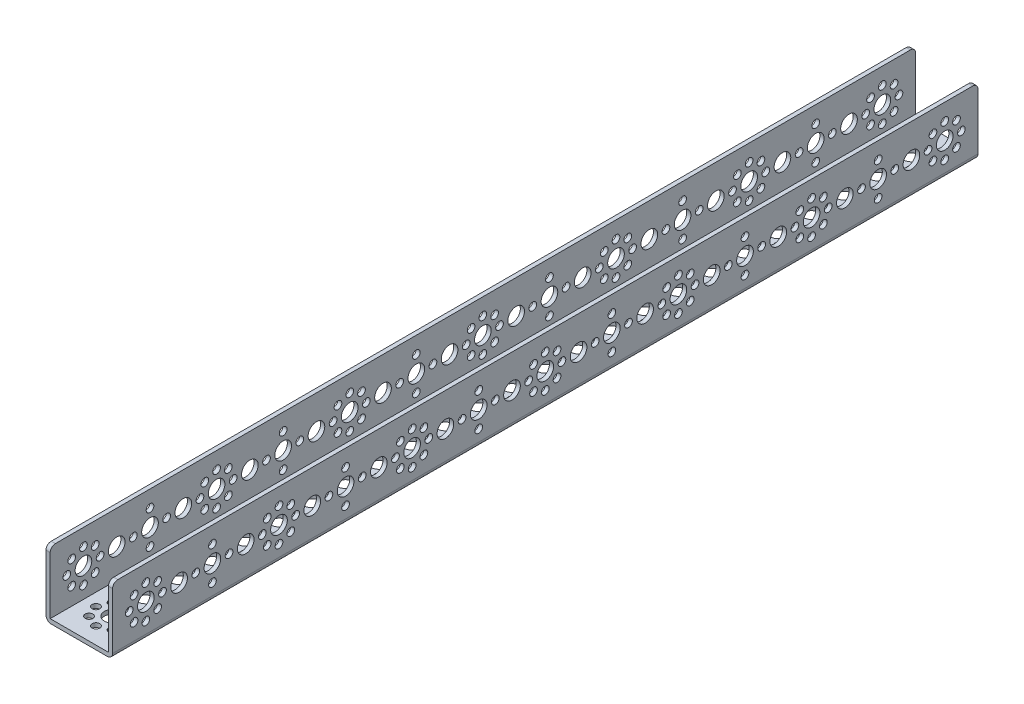
from build123d import *

# Parameters (mm, degrees)
SKETCH1_W                      = 32
SKETCH1_H                      = 416
BOSS_EXTRUDE1_DEPTH            = 32
SKETCH2_W                      = 28
SKETCH2_H                      = 30
CUT_EXTRUDE1_DEPTH             = 417
F_8_0_8_DIAMETER_HOLE1_D       = 8
F_8_0_8_DIAMETER_HOLE1_DEPTH   = 2
F_8_0_8_DIAMETER_HOLE2_D       = 8
F_8_0_8_DIAMETER_HOLE2_DEPTH   = 2
F_3_7_3_7_DIAMETER_HOLE1_D     = 3.7
F_3_7_3_7_DIAMETER_HOLE1_DEPTH = 2
F_3_7_3_7_DIAMETER_HOLE2_D     = 3.7
F_3_7_3_7_DIAMETER_HOLE2_DEPTH = 32
F_8_0_8_DIAMETER_HOLE3_D       = 8
F_8_0_8_DIAMETER_HOLE3_DEPTH   = 32
F_8_0_8_DIAMETER_HOLE4_D       = 8
F_8_0_8_DIAMETER_HOLE4_DEPTH   = 32
F_3_7_3_7_DIAMETER_HOLE3_D     = 3.7
F_3_7_3_7_DIAMETER_HOLE3_DEPTH = 32
FILLET1_R                      = 2.5


with BuildPart() as part:
    # Sketch1 → Boss-Extrude1 (new body)
    with BuildSketch(Plane(origin=(-16, 0, 0), x_dir=(0, -1, 0), z_dir=(-1, 0, 0))):
        with Locations((-16, -192)):
            Rectangle(SKETCH1_W, SKETCH1_H)
    extrude(amount=-BOSS_EXTRUDE1_DEPTH)

    # Sketch2 → Cut-Extrude1 (cut, through all)
    with BuildSketch(Plane.XY.offset(16)):
        with Locations((0, 17)):
            Rectangle(SKETCH2_W, SKETCH2_H)
    extrude(amount=-CUT_EXTRUDE1_DEPTH, mode=Mode.SUBTRACT)

    # Ø8.0 (8) Diameter Hole1
    with Locations(Plane.ZY.offset(-14)):
        with Locations((-32, 16)):
            Hole(F_8_0_8_DIAMETER_HOLE1_D / 2, depth=F_8_0_8_DIAMETER_HOLE1_DEPTH)

    # Ø8.0 (8) Diameter Hole2
    with Locations(Plane(origin=(16, 0, 0), x_dir=(0, 0, -1), z_dir=(1, 0, 0))):
        with Locations((64, 16), (128, 16), (192, 16), (256, 16), (320, 16), (384, 16), (96, 16), (160, 16), (224, 16), (288, 16), (352, 16), (16, 16), (48, 16), (80, 16), (112, 16), (144, 16), (176, 16), (208, 16), (240, 16), (0, 16), (272, 16), (304, 16), (336, 16), (368, 16)):
            Hole(F_8_0_8_DIAMETER_HOLE2_D / 2, depth=F_8_0_8_DIAMETER_HOLE2_DEPTH)

    # Ø3.7 (3.7) Diameter Hole1
    with Locations(Plane(origin=(16, 0, 0), x_dir=(0, 0, -1), z_dir=(1, 0, 0))):
        with Locations((0, 24), (0, 8), (8, 16), (-8, 16), (5.656854249, 21.656854249), (-5.656854249, 21.656854249), (-5.656854249, 10.343145751), (5.656854249, 10.343145751), (64, 24), (64, 8), (72, 16), (56, 16), (69.656854249, 21.656854249), (58.343145751, 21.656854249), (58.343145751, 10.343145751), (69.656854249, 10.343145751), (128, 24), (128, 8), (136, 16), (120, 16), (133.656854249, 21.656854249), (122.34314575, 21.656854249), (122.34314575, 10.343145751), (133.656854249, 10.343145751), (192, 24), (192, 8), (200, 16), (184, 16), (197.656854249, 21.656854249), (186.343145751, 21.656854249), (186.343145751, 10.343145751), (197.656854249, 10.343145751), (256, 24), (256, 8), (264, 16), (248, 16), (261.656854249, 21.656854249), (250.343145751, 21.656854249), (250.343145751, 10.343145751), (261.656854249, 10.343145751), (320, 24), (320, 8), (328, 16), (312, 16), (325.656854249, 21.656854249), (314.343145751, 21.656854249), (314.343145751, 10.343145751), (325.656854249, 10.343145751), (384, 24), (384, 8), (392, 16), (376, 16), (389.656854249, 21.656854249), (378.343145751, 21.656854249), (378.343145751, 10.343145751), (389.656854249, 10.343145751), (32, 24), (40, 16), (32, 8), (24, 16), (96, 24), (104, 16), (96, 8), (88, 16), (160, 24), (168, 16), (160, 8), (152, 16), (224, 24), (232, 16), (224, 8), (216, 16), (288, 24), (296, 16), (288, 8), (280, 16), (352, 24), (360, 16), (352, 8), (344, 16)):
            Hole(F_3_7_3_7_DIAMETER_HOLE1_D / 2, depth=F_3_7_3_7_DIAMETER_HOLE1_DEPTH)

    # Ø3.7 (3.7) Diameter Hole2
    with Locations(Plane(origin=(0, 0, 0), x_dir=(-1, 0, 0), z_dir=(0, -1, 0))):
        with Locations((8, 0), (5.656854249, 5.656854249), (0, 8), (-5.656854249, 5.656854249), (-8, 0), (-5.656854249, -5.656854249), (0, -8), (5.656854249, -5.656854249), (8, 64), (5.656854249, 69.656854249), (0, 72), (-5.656854249, 69.656854249), (-8, 64), (-5.656854249, 58.343145751), (0, 56), (5.656854249, 58.343145751), (8, 128), (5.656854249, 133.656854249), (0, 136), (-5.656854249, 133.656854249), (-8, 128), (-5.656854249, 122.34314575), (0, 120), (5.656854249, 122.34314575), (8, 192), (5.656854249, 197.656854249), (0, 200), (-5.656854249, 197.656854249), (-8, 192), (-5.656854249, 186.343145751), (0, 184), (5.656854249, 186.343145751), (8, 256), (5.656854249, 261.656854249), (0, 264), (-5.656854249, 261.656854249), (-8, 256), (-5.656854249, 250.343145751), (0, 248), (5.656854249, 250.343145751), (8, 320), (5.656854249, 325.656854249), (0, 328), (-5.656854249, 325.656854249), (-8, 320), (-5.656854249, 314.343145751), (0, 312), (5.656854249, 314.343145751), (8, 384), (5.656854249, 389.656854249), (0, 392), (-5.656854249, 389.656854249), (-8, 384), (-5.656854249, 378.343145751), (0, 376), (5.656854249, 378.343145751), (8, 32), (0, 40), (-8, 32), (0, 24), (8, 96), (0, 104), (-8, 96), (0, 88), (8, 160), (0, 168), (-8, 160), (0, 152), (8, 224), (0, 232), (-8, 224), (0, 216), (8, 288), (0, 296), (-8, 288), (0, 280), (8, 352), (0, 360), (-8, 352), (0, 344)):
            Hole(F_3_7_3_7_DIAMETER_HOLE2_D / 2, depth=F_3_7_3_7_DIAMETER_HOLE2_DEPTH)

    # Ø8.0 (8) Diameter Hole3
    with Locations(Plane(origin=(0, 0, 0), x_dir=(-1, 0, 0), z_dir=(0, -1, 0))):
        with Locations((0, 0), (0, 64), (0, 128), (0, 192), (0, 256), (0, 320), (0, 384), (0, 32), (0, 96), (0, 160), (0, 224), (0, 288), (0, 352), (0, 16), (0, 48), (0, 80), (0, 112), (0, 144), (0, 176), (0, 208), (0, 240), (0, 272), (0, 304), (0, 336), (0, 368)):
            Hole(F_8_0_8_DIAMETER_HOLE3_D / 2, depth=F_8_0_8_DIAMETER_HOLE3_DEPTH)

    # Ø8.0 (8) Diameter Hole4
    with Locations(Plane.ZY.offset(16)):
        with Locations((-64, 16), (-128, 16), (-192, 16), (-256, 16), (-320, 16), (-384, 16), (-32, 16), (-96, 16), (-160, 16), (-224, 16), (-288, 16), (-352, 16), (-16, 16), (-48, 16), (-80, 16), (-112, 16), (-144, 16), (-176, 16), (-208, 16), (-240, 16), (0, 16), (-272, 16), (-304, 16), (-336, 16), (-368, 16)):
            Hole(F_8_0_8_DIAMETER_HOLE4_D / 2, depth=F_8_0_8_DIAMETER_HOLE4_DEPTH)

    # Ø3.7 (3.7) Diameter Hole3
    with Locations(Plane.ZY.offset(16)):
        with Locations((0, 24), (0, 8), (-8, 16), (8, 16), (-5.656854249, 21.656854249), (5.656854249, 21.656854249), (5.656854249, 10.343145751), (-5.656854249, 10.343145751), (-64, 24), (-64, 8), (-72, 16), (-56, 16), (-69.656854249, 21.656854249), (-58.343145751, 21.656854249), (-58.343145751, 10.343145751), (-69.656854249, 10.343145751), (-128, 24), (-128, 8), (-136, 16), (-120, 16), (-133.656854249, 21.656854249), (-122.34314575, 21.656854249), (-122.34314575, 10.343145751), (-133.656854249, 10.343145751), (-192, 24), (-192, 8), (-200, 16), (-184, 16), (-197.656854249, 21.656854249), (-186.343145751, 21.656854249), (-186.343145751, 10.343145751), (-197.656854249, 10.343145751), (-256, 24), (-256, 8), (-264, 16), (-248, 16), (-261.656854249, 21.656854249), (-250.343145751, 21.656854249), (-250.343145751, 10.343145751), (-261.656854249, 10.343145751), (-320, 24), (-320, 8), (-328, 16), (-312, 16), (-325.656854249, 21.656854249), (-314.343145751, 21.656854249), (-314.343145751, 10.343145751), (-325.656854249, 10.343145751), (-384, 24), (-384, 8), (-392, 16), (-376, 16), (-389.656854249, 21.656854249), (-378.343145751, 21.656854249), (-378.343145751, 10.343145751), (-389.656854249, 10.343145751), (-32, 24), (-40, 16), (-32, 8), (-24, 16), (-96, 24), (-104, 16), (-96, 8), (-88, 16), (-160, 24), (-168, 16), (-160, 8), (-152, 16), (-224, 24), (-232, 16), (-224, 8), (-216, 16), (-288, 24), (-296, 16), (-288, 8), (-280, 16), (-352, 24), (-360, 16), (-352, 8), (-344, 16)):
            Hole(F_3_7_3_7_DIAMETER_HOLE3_D / 2, depth=F_3_7_3_7_DIAMETER_HOLE3_DEPTH)

    # Fillet1
    fillet1_edges = [part.edges().sort_by_distance(p)[0] for p in [
        (16, 0, -192),
        (-15, 32, -400),
        (-15, 32, 16),
        (-16, 0, -192),
        (15, 32, 16),
        (15, 32, -400),
    ]]
    fillet(fillet1_edges, radius=FILLET1_R)


solid = part.part
